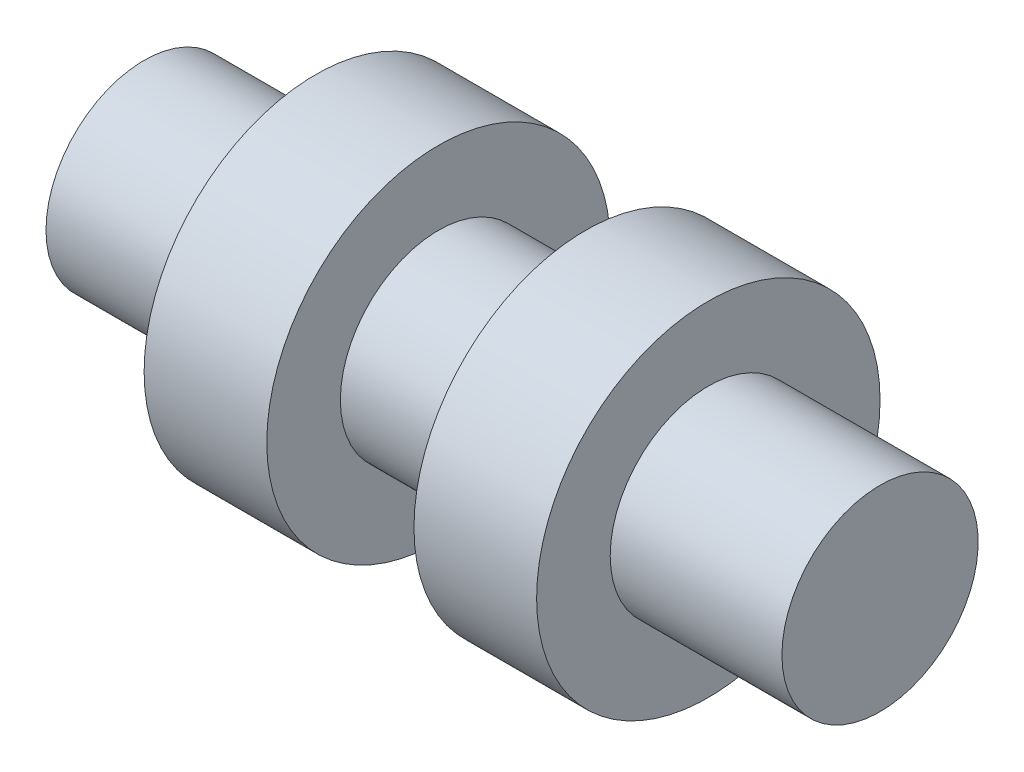
from build123d import *


with BuildPart() as part:
    # 스케치1 → 회전1 (revolve)
    with BuildSketch(Plane.XY):
        Polygon((15, 20), (-15, 20), (-15, 35), (-40, 35), (-40, 20), (-75, 20), (-75, 0), (0, 0), (75, 0), (75, 20), (40, 20), (40, 35), (15, 35), align=None)
    revolve(axis=Axis((0, 0, 0), (1, 0, 0)))


solid = part.part
